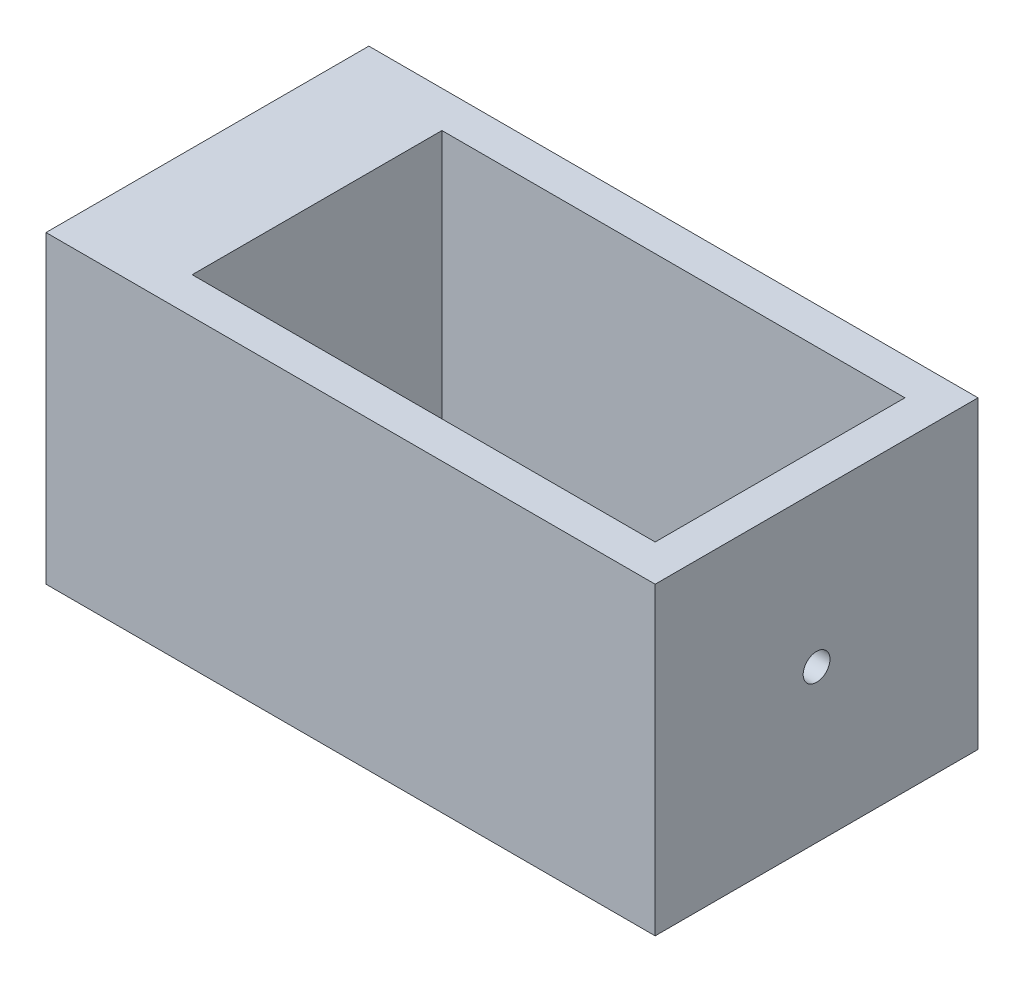
from build123d import *

# Parameters (mm, degrees)
SKETCH_2_W          = 76
SKETCH_2_H          = 41
EXTRUDE_1_DEPTH     = 50
CUT_EXTRUDE_1_REACH = 102
SKETCH_3_R          = 2.2


with BuildPart() as part:
    # 草图2 → 凸台-拉伸1 (new body)
    with BuildSketch(Plane(origin=(0, 0, 0), x_dir=(1, 0, 0), z_dir=(0, 1, 0))):
        Polygon((-38, -26.5), (44, -26.5), (44, 26.5), (-38, 26.5), (-56, 26.5), (-56, -26.5), align=None)
        Rectangle(SKETCH_2_W, SKETCH_2_H, mode=Mode.SUBTRACT)
    extrude(amount=EXTRUDE_1_DEPTH)

    # 草图3 → 切除-拉伸1 (cut, up to next)
    with BuildSketch(Plane(origin=(44, 0, 0), x_dir=(0, 0, -1), z_dir=(1, 0, 0)), mode=Mode.PRIVATE) as cut_extrude_1_sk1:
        with Locations((0, 25)):
            Circle(SKETCH_3_R)
    cut_extrude_1_tool1 = extrude(cut_extrude_1_sk1.sketch, amount=-CUT_EXTRUDE_1_REACH, mode=Mode.PRIVATE) & part.part
    add(cut_extrude_1_tool1.solids().sort_by_distance((44, 25, 0))[0], mode=Mode.SUBTRACT)


solid = part.part
